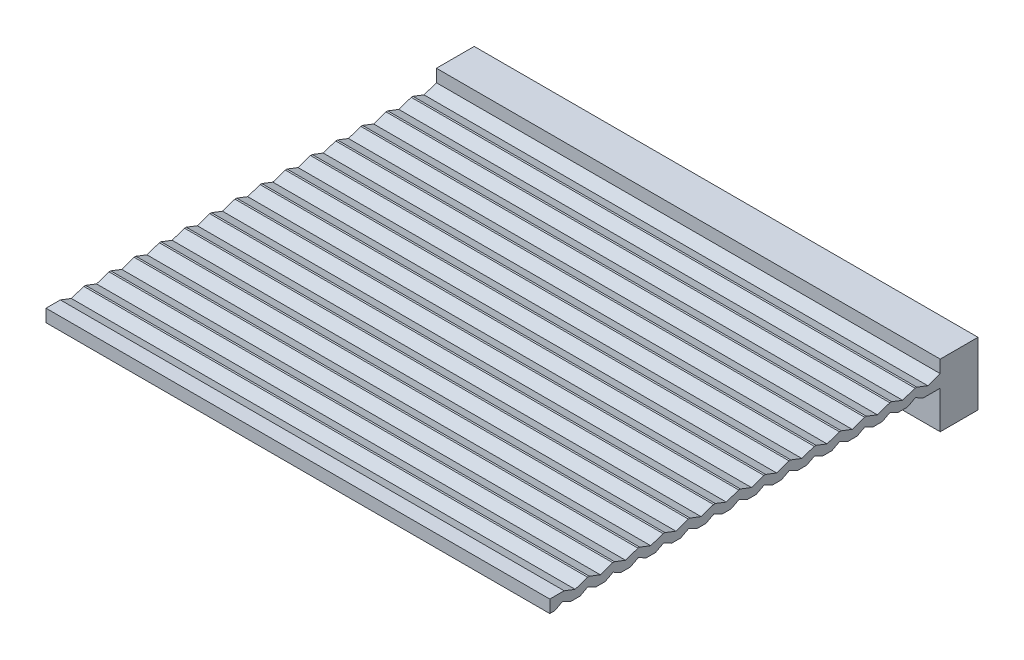
from build123d import *

# Parameters (mm, degrees)
SKETCH1_W           = 400
SKETCH1_H           = 30
BOSS_EXTRUDE1_DEPTH = 50
SKETCH2_W           = 400
SKETCH2_H           = 10
BOSS_EXTRUDE2_DEPTH = 310
CUT_EXTRUDE1_DEPTH  = 400
LPATTERN1_COUNT     = 15
LPATTERN1_PITCH     = 20


with BuildPart() as part:
    # Sketch1 → Boss-Extrude1 (new body)
    with BuildSketch(Plane(origin=(0, 0, 0), x_dir=(1, 0, 0), z_dir=(0, 1, 0))):
        with Locations((200, 15)):
            Rectangle(SKETCH1_W, SKETCH1_H)
    extrude(amount=BOSS_EXTRUDE1_DEPTH)

    # Sketch2 → Boss-Extrude2 (add)
    with BuildSketch(Plane.XY):
        with Locations((200, 35)):
            Rectangle(SKETCH2_W, SKETCH2_H)
    extrude(amount=BOSS_EXTRUDE2_DEPTH)

    # Sketch3 → Cut-Extrude1 (cut)
    with BuildSketch(Plane.ZY):
        Polygon((0, 40), (9.867375243, 36.624338333), (18.617949732, 40), align=None)
        Polygon((13.283352971, 30), (19.738366334, 33.302751996), (26.012819883, 30), align=None)
    cut_extrude1 = extrude(amount=-CUT_EXTRUDE1_DEPTH, mode=Mode.SUBTRACT)

    # LPattern1: Cut-Extrude1 ×15
    with Locations(*[(0, 0, i * LPATTERN1_PITCH) for i in range(1, LPATTERN1_COUNT)]):
        add(cut_extrude1, mode=Mode.SUBTRACT)


solid = part.part
